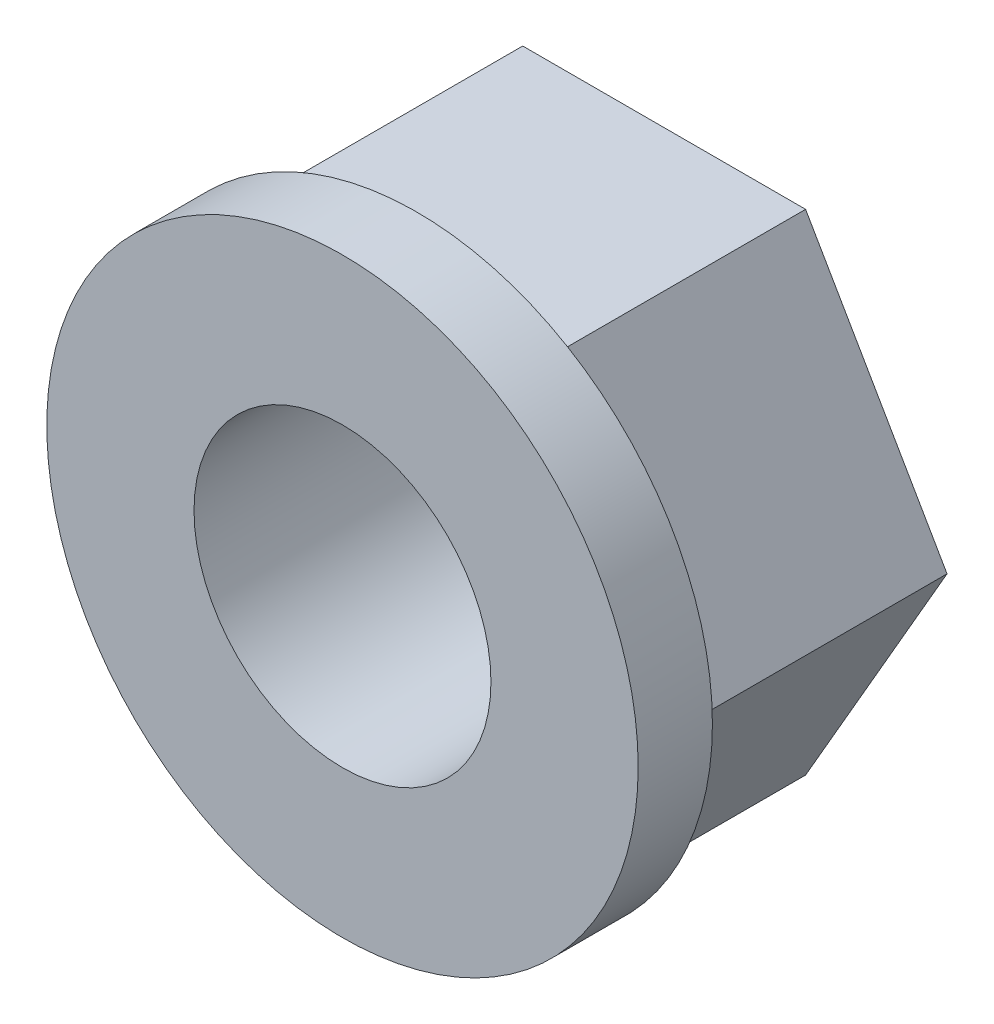
from build123d import *

# Parameters (mm, degrees)
SKETCH1_R           = 3
BOSS_EXTRUDE1_DEPTH = 5
SKETCH2_R           = 5.975
SKETCH2_R_2         = 3
BOSS_EXTRUDE2_DEPTH = 1.5


with BuildPart() as part:
    # Sketch1 → Boss-Extrude1 (new body)
    with BuildSketch(Plane.XY):
        Polygon((-5.715767665, 0), (-2.857883832, -4.95), (2.857883832, -4.95), (5.715767665, 0), (2.857883832, 4.95), (-2.857883832, 4.95), align=None)
        Circle(SKETCH1_R, mode=Mode.SUBTRACT)
    extrude(amount=BOSS_EXTRUDE1_DEPTH)

    # Sketch2 → Boss-Extrude2 (add)
    with BuildSketch(Plane.XY.offset(5)):
        Circle(SKETCH2_R)
        Circle(SKETCH2_R_2, mode=Mode.SUBTRACT)
    extrude(amount=BOSS_EXTRUDE2_DEPTH)


solid = part.part
